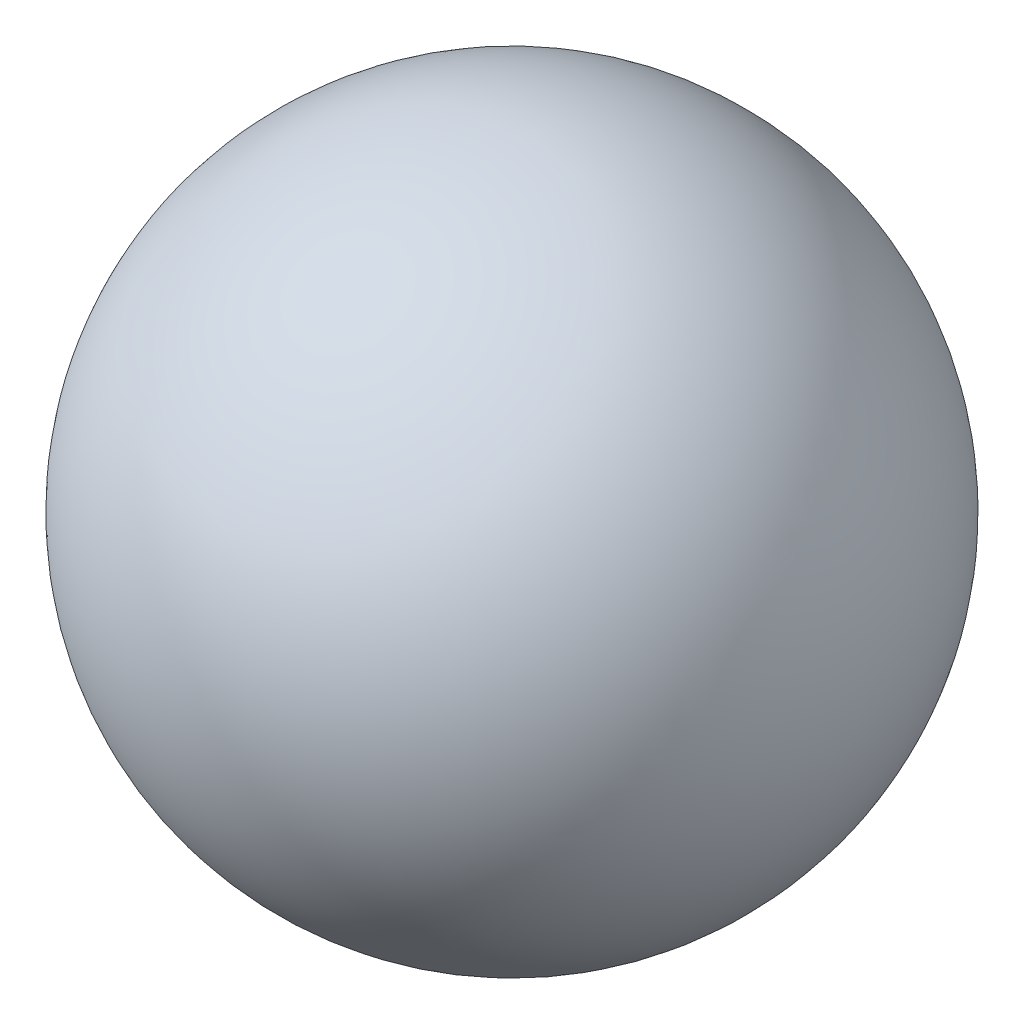
from build123d import *


with BuildPart() as part:
    # Sketch3 → Revolve1 (revolve)
    with BuildSketch(Plane.XY):
        with BuildLine():
            Line((-7.9375, 0), (7.9375, 0))
            ThreePointArc((7.9375, 0), (0, 7.9375), (-7.9375, 0))
        make_face()
    revolve(axis=Axis((-7.9375, 0, 0), (1, 0, 0)))


solid = part.part
